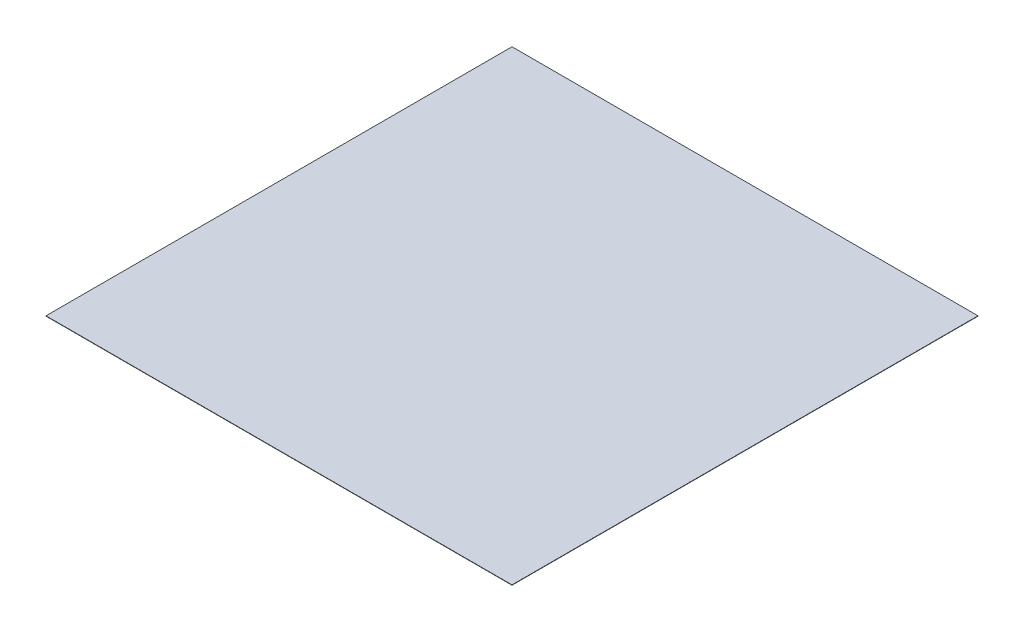
from build123d import *

# Parameters (mm, degrees)
SKETCH1_W           = 95.25
SKETCH1_H           = 95.25
BOSS_EXTRUDE1_DEPTH = 0.065


with BuildPart() as part:
    # Sketch1 → Boss-Extrude1 (new body)
    with BuildSketch(Plane(origin=(0, 0, 0), x_dir=(1, 0, 0), z_dir=(0, 1, 0))):
        Rectangle(SKETCH1_W, SKETCH1_H)
    extrude(amount=BOSS_EXTRUDE1_DEPTH)


solid = part.part
